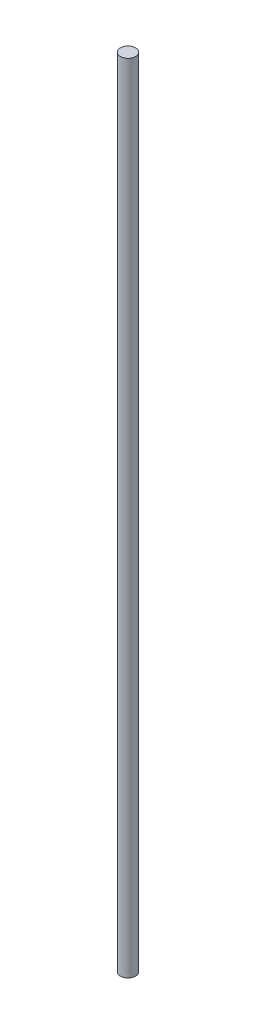
from build123d import *

# Parameters (mm, degrees)
SKETCH1_R           = 2
BOSS_EXTRUDE1_DEPTH = 210


with BuildPart() as part:
    # Sketch1 → Boss-Extrude1 (new body)
    with BuildSketch(Plane(origin=(0, 0, 0), x_dir=(1, 0, 0), z_dir=(0, 1, 0))):
        Circle(SKETCH1_R)
    extrude(amount=BOSS_EXTRUDE1_DEPTH)


solid = part.part
